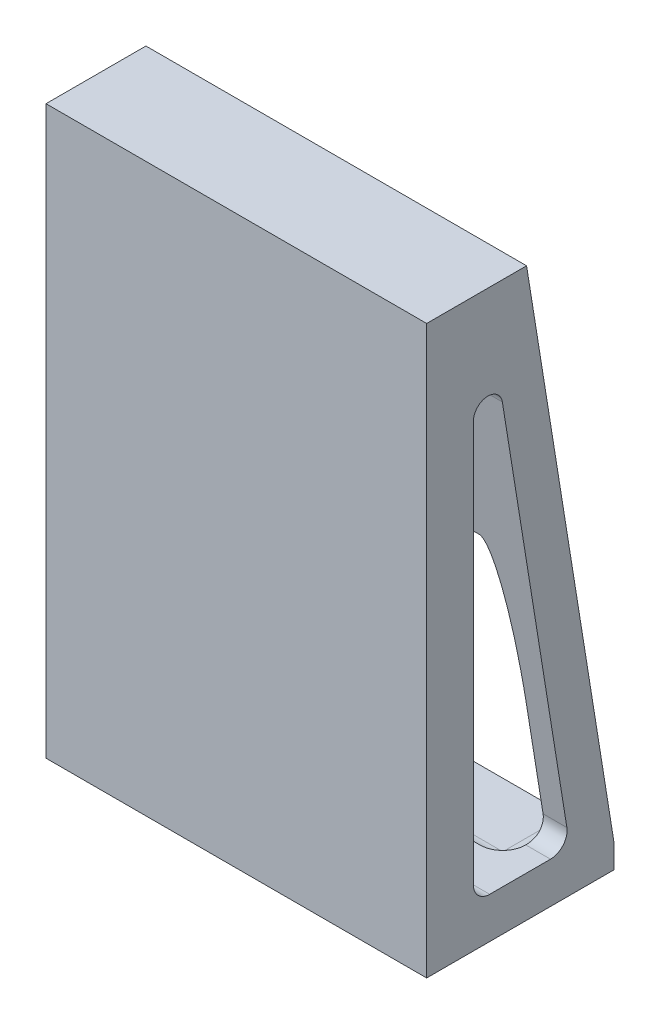
from build123d import *

# Parameters (mm, degrees)
SKETCH1_W                       = 152.4
SKETCH1_H                       = 40
BOSS_EXTRUDE1_DEPTH             = 179.05
BOSS_EXTRUDE1_DEPTH_BACK        = 100
BOSS_EXTRUDE2_REACH             = 200.659
SKETCH3_W                       = 75
SKETCH3_H                       = 9.525
BOSS_EXTRUDE2_DIRECTION_2_REACH = 200.659
RIB1_REACH                      = 248.799
SKETCH4_WALL_W                  = 715.816770022
SKETCH4_WALL_H                  = 9.525
FILLET1_R                       = 9.525
CUT_EXTRUDE1_REACH              = 210.543
CUT_EXTRUDE1_DIRECTION_2_REACH  = 210.543


with BuildPart() as part:
    # Sketch1 → Boss-Extrude1 (new, two sides)
    with BuildSketch(Plane(origin=(0, 0, 0), x_dir=(1, 0, 0), z_dir=(0, 1, 0))) as boss_extrude1_sk:
        with Locations((0, 20)):
            Rectangle(SKETCH1_W, SKETCH1_H)
    extrude(amount=BOSS_EXTRUDE1_DEPTH)
    extrude(boss_extrude1_sk.sketch, amount=-BOSS_EXTRUDE1_DEPTH_BACK)

    # SurfaceCut1
    split(bisect_by=Plane(origin=(0, -47.895, 0), x_dir=(1, 0, 0), z_dir=(0, 1, 0)), keep=Keep.TOP)

    # Boss-Extrude2: up to this face of the body (flat: up to its plane)
    boss_extrude2_end = Plane(part.part.faces().sort_by_distance((76.2, 65.5775, -20))[0])
    # Sketch3 → Boss-Extrude2 (add, up to the picked face)
    with BuildSketch(Plane(origin=(0, 0, 0), x_dir=(0, 0, -1), z_dir=(1, 0, 0)), mode=Mode.PRIVATE) as boss_extrude2_sk1:
        with Locations((37.5, -43.1325)):
            Rectangle(SKETCH3_W, SKETCH3_H)
    boss_extrude2_tool1 = split(extrude(boss_extrude2_sk1.sketch, amount=BOSS_EXTRUDE2_REACH, mode=Mode.PRIVATE), bisect_by=boss_extrude2_end, keep=Keep.BOTH, mode=Mode.PRIVATE)
    add(boss_extrude2_tool1.solids().sort_by(Axis((0, -43.1325, -37.5), (1, 0, 0)))[0])

    # Boss-Extrude2 direction 2: up to this face of the body (flat: up to its plane)
    boss_extrude2_direction_2_end = Plane(part.part.faces().sort_by_distance((-76.2, 65.5775, -20))[0])
    # Sketch3 → Boss-Extrude2 direction 2 (add, up to the picked face)
    with BuildSketch(Plane(origin=(0, 0, 0), x_dir=(0, 0, -1), z_dir=(1, 0, 0)), mode=Mode.PRIVATE) as boss_extrude2_direction_2_sk1:
        with Locations((37.5, -43.1325)):
            Rectangle(SKETCH3_W, SKETCH3_H)
    boss_extrude2_direction_2_tool1 = split(extrude(boss_extrude2_direction_2_sk1.sketch, amount=-BOSS_EXTRUDE2_DIRECTION_2_REACH, mode=Mode.PRIVATE), bisect_by=boss_extrude2_direction_2_end, keep=Keep.BOTH, mode=Mode.PRIVATE)
    add(boss_extrude2_direction_2_tool1.solids().sort_by(Axis((0, -43.1325, -37.5), (-1, 0, 0)))[0])

    # Sketch4 wall → Rib1 (add, up to next)
    with BuildSketch(Plane(origin=(76.2, 70.34, -57.5), x_dir=(0, -0.987289431969, -0.158932619441), z_dir=(0, 0.158932619441, -0.987289431969)), mode=Mode.PRIVATE) as rib1_sk1:
        with Locations((0, 4.7625)):
            Rectangle(SKETCH4_WALL_W, SKETCH4_WALL_H)
    rib1_tool1 = extrude(rib1_sk1.sketch, amount=-RIB1_REACH, mode=Mode.PRIVATE) - part.part
    rib1 = rib1_tool1.solids().sort_by_distance((76.2, 70.34, -57.5))[0]
    add(rib1)

    # Mirror1: Rib1 across plane
    add(rib1.mirror(Plane(origin=(0, 0, 0), x_dir=(0, 0, 1), z_dir=(1, 0, 0))))

    # Fillet1
    fillet1_edges = [part.edges().sort_by_distance(p)[0] for p in [
        (0, -38.37, -40),
        (66.675, -38.37, -57.5),
        (66.675, 70.34, -40),
        (-66.675, 70.34, -40),
        (-66.675, -38.37, -57.5),
    ]]
    fillet(fillet1_edges, radius=FILLET1_R)

    # Cut-Extrude1: up to this face of the body (flat: up to its plane)
    cut_extrude1_end = Plane(part.part.faces().sort_by_distance((-76.2, 53.773975166, -30.062668553))[0])
    # Sketch8 → Cut-Extrude1 (cut, up to the picked face)
    with BuildSketch(Plane(origin=(0, 0, 0), x_dir=(0, 0, -1), z_dir=(1, 0, 0)), mode=Mode.PRIVATE) as cut_extrude1_sk1:
        with BuildLine():
            Line((25.236746286, -31.487519231), (49.576175238, -31.487519231))
            ThreePointArc((49.576175238, -31.487519231), (54.633662665, -29.152106057), (56.135591687, -23.787728834))
            Line((56.135591687, -23.787728834), (30.301291161, 136.694946031))
            ThreePointArc((30.301291161, 136.694946031), (24.071010718, 141.587364194), (18.697485511, 135.766936654))
            Line((18.697485511, 135.766936654), (18.697485511, -24.948258456))
            ThreePointArc((18.697485511, -24.948258456), (20.612790648, -29.572214094), (25.236746286, -31.487519231))
        make_face()
    cut_extrude1_tool1 = split(extrude(cut_extrude1_sk1.sketch, amount=-CUT_EXTRUDE1_REACH, mode=Mode.PRIVATE), bisect_by=cut_extrude1_end, keep=Keep.BOTH, mode=Mode.PRIVATE)
    add(cut_extrude1_tool1.solids().sort_by(Axis((0, 38.89099, -32.356169), (-1, 0, 0)))[0], mode=Mode.SUBTRACT)

    # Cut-Extrude1 direction 2: up to this face of the body (flat: up to its plane)
    cut_extrude1_direction_2_end = Plane(part.part.faces().sort_by_distance((76.2, 53.773975166, -30.062668553))[0])
    # Sketch8 → Cut-Extrude1 direction 2 (cut, up to the picked face)
    with BuildSketch(Plane(origin=(0, 0, 0), x_dir=(0, 0, -1), z_dir=(1, 0, 0)), mode=Mode.PRIVATE) as cut_extrude1_direction_2_sk1:
        with BuildLine():
            Line((25.236746286, -31.487519231), (49.576175238, -31.487519231))
            ThreePointArc((49.576175238, -31.487519231), (54.633662665, -29.152106057), (56.135591687, -23.787728834))
            Line((56.135591687, -23.787728834), (30.301291161, 136.694946031))
            ThreePointArc((30.301291161, 136.694946031), (24.071010718, 141.587364194), (18.697485511, 135.766936654))
            Line((18.697485511, 135.766936654), (18.697485511, -24.948258456))
            ThreePointArc((18.697485511, -24.948258456), (20.612790648, -29.572214094), (25.236746286, -31.487519231))
        make_face()
    cut_extrude1_direction_2_tool1 = split(extrude(cut_extrude1_direction_2_sk1.sketch, amount=CUT_EXTRUDE1_DIRECTION_2_REACH, mode=Mode.PRIVATE), bisect_by=cut_extrude1_direction_2_end, keep=Keep.BOTH, mode=Mode.PRIVATE)
    add(cut_extrude1_direction_2_tool1.solids().sort_by(Axis((0, 38.89099, -32.356169), (1, 0, 0)))[0], mode=Mode.SUBTRACT)


solid = part.part
